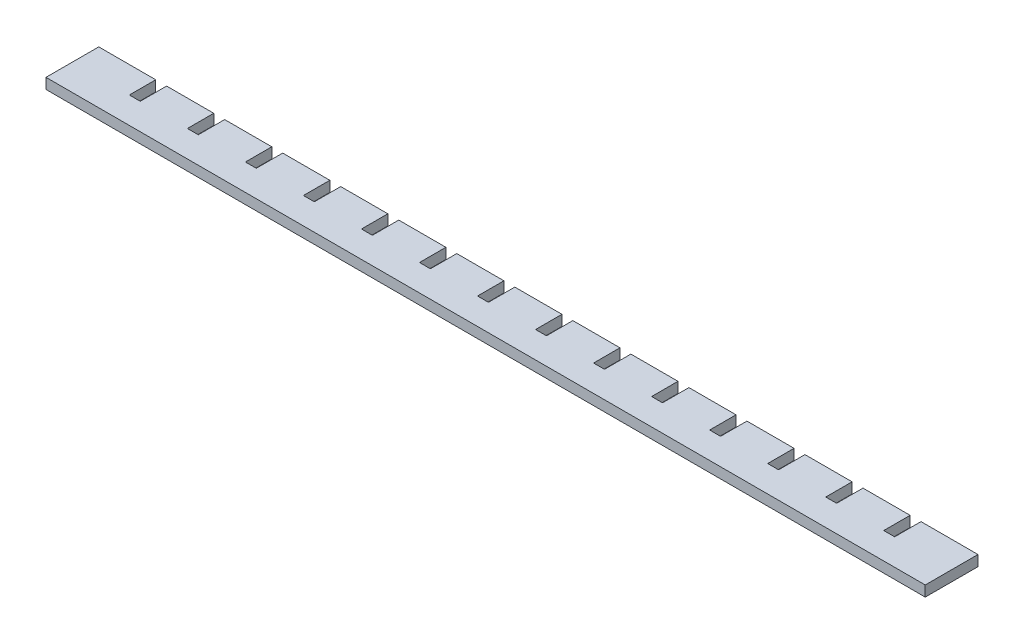
from build123d import *

# Parameters (mm, degrees)
AUFSATZ_LINEAR_AUSTRAGEN1_DEPTH = 3


with BuildPart() as part:
    # Skizze1 → Aufsatz-Linear austragen1 (new body)
    with BuildSketch(Plane(origin=(0, 0, 0), x_dir=(1, 0, 0), z_dir=(0, 1, 0))):
        Polygon((4.885929648, 7.801507538), (4.885929648, 0.301507538), (7.985929648, 0.301507538), (7.985929648, 7.801507538), (21.385929648, 7.801507538), (21.385929648, 0.301507538), (24.485929648, 0.301507538), (24.485929648, 7.801507538), (37.885929648, 7.801507538), (37.885929648, 0.301507538), (40.985929648, 0.301507538), (40.985929648, 7.801507538), (54.385929648, 7.801507538), (54.385929648, 0.301507538), (57.485929648, 0.301507538), (57.485929648, 7.801507538), (70.885929648, 7.801507538), (70.885929648, 0.301507538), (73.985929648, 0.301507538), (73.985929648, 7.801507538), (87.385929648, 7.801507538), (87.385929648, 0.301507538), (90.485929648, 0.301507538), (90.485929648, 7.801507538), (103.885929648, 7.801507538), (103.885929648, 0.301507538), (106.985929648, 0.301507538), (106.985929648, 7.801507538), (120.385929648, 7.801507538), (120.385929648, 0.301507538), (123.485929648, 0.301507538), (123.485929648, 7.801507538), (136.885929648, 7.801507538), (136.885929648, 0.301507538), (139.985929648, 0.301507538), (139.985929648, 7.801507538), (153.385929648, 7.801507538), (153.385929648, 0.301507538), (156.485929648, 0.301507538), (156.485929648, 7.801507538), (169.885929648, 7.801507538), (169.885929648, 0.301507538), (172.985929648, 0.301507538), (172.985929648, 7.801507538), (186.385929648, 7.801507538), (186.385929648, 0.301507538), (189.485929648, 0.301507538), (189.485929648, 7.801507538), (202.885929648, 7.801507538), (202.885929648, 0.301507538), (205.985929648, 0.301507538), (205.985929648, 7.801507538), (222.185929648, 7.801507538), (222.185929648, -7.198492462), (-27.814070352, -7.198492462), (-27.814070352, 7.801507538), (-11.614070352, 7.801507538), (-11.614070352, 0.301507538), (-8.514070352, 0.301507538), (-8.514070352, 7.801507538), align=None)
    extrude(amount=AUFSATZ_LINEAR_AUSTRAGEN1_DEPTH)


solid = part.part
